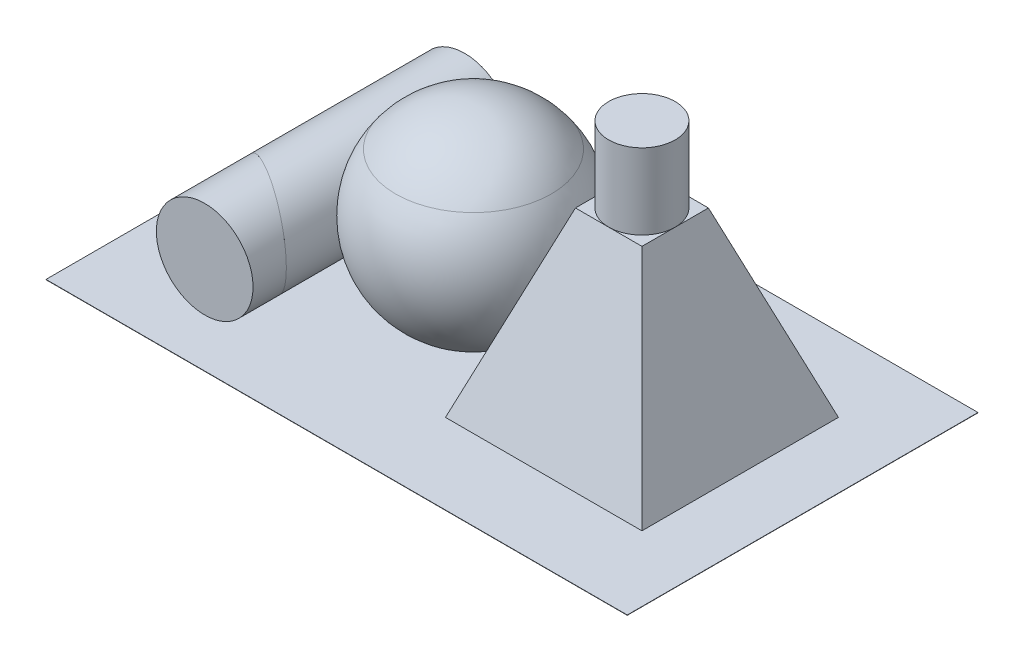
from build123d import *

# Parameters (mm, degrees)
BOSS_EXTRUDE1_DEPTH = 32.5
CUT_EXTRUDE1_DEPTH  = 95.240384125
SKETCH5_R           = 16
BOSS_EXTRUDE2_DEPTH = 43
CUT_EXTRUDE2_DEPTH  = 114.773628326
BOSS_EXTRUDE3_REACH = 137.983
SKETCH7_R           = 16
SKETCH8_R           = 11
BOSS_EXTRUDE4_DEPTH = 25
SKETCH9_W           = 192.296560702
SKETCH9_H           = 116.033958803
BOSS_EXTRUDE5_DEPTH = 0.1


with BuildPart() as part:
    # Sketch1 → Boss-Extrude1 (new, symmetric)
    with BuildSketch(Plane.XY):
        Polygon((0, 0), (65, 0), (43.5, 60), (21.5, 60), align=None)
    extrude(amount=BOSS_EXTRUDE1_DEPTH, both=True)

    # Sketch2 → Cut-Extrude1 (cut, through all)
    with BuildSketch(Plane(origin=(0, 0, 0), x_dir=(0, 0, -1), z_dir=(1, 0, 0))):
        Polygon((11, 60), (32.5, 60), (32.5, 0), align=None)
        Polygon((-32.5, 0), (-11, 60), (-32.5, 60), align=None)
    extrude(amount=CUT_EXTRUDE1_DEPTH, mode=Mode.SUBTRACT)

    # Sketch8 → Boss-Extrude4 (add)
    with BuildSketch(Plane(origin=(0, 60, 0), x_dir=(1, 0, 0), z_dir=(0, 1, 0))):
        with Locations(Location((32.5, 0, 0), (0, 0, 270))):
            Circle(SKETCH8_R)
    extrude(amount=BOSS_EXTRUDE4_DEPTH)


with BuildPart() as body_2:
    # Sketch3 → Revolve1 (revolve)
    with BuildSketch(Plane.XY):
        with BuildLine():
            Line((-12.106888729, 0), (-23.242417455, 0))
            Line((-23.242417455, 0), (-23.242417455, 49))
            Line((-23.242417455, 49), (2.506368924, 49))
            ThreePointArc((2.506368924, 49), (7.422924141, 20.854682903), (-12.106888729, 0))
        make_face()
    revolve(axis=Axis((-23.242417455, 0, 0), (0, 1, 0)))


with BuildPart() as body_3:
    # Sketch4 → Revolve2 (revolve)
    with BuildSketch(Plane.XY):
        with BuildLine():
            Line((-23.242417455, 49), (2.506368924, 49))
            ThreePointArc((2.506368924, 49), (-8.820212353, 58.565713714), (-23.242417455, 62))
            Line((-23.242417455, 62), (-23.242417455, 49))
        make_face()
    revolve(axis=Axis((-23.242417455, 49, 0), (0, 1, 0)))


with BuildPart() as body_4:
    # Sketch5 → Boss-Extrude2 (new, symmetric)
    with BuildSketch(Plane.XY):
        with Locations((-69.155378588, 16)):
            Circle(SKETCH5_R)
    extrude(amount=BOSS_EXTRUDE2_DEPTH, both=True)

    # Sketch6 → Cut-Extrude2 (cut, through all)
    with BuildSketch(Plane(origin=(0, 0, 0), x_dir=(1, 0, 0), z_dir=(0, 1, 0))):
        Polygon((-53.155378588, -32), (-93.662728042, -8.613070889), (-93.662728042, -63.183775795), (-40.15438586, -61.061315458), align=None)
    extrude(amount=CUT_EXTRUDE2_DEPTH, mode=Mode.SUBTRACT)


with BuildPart() as body_5:
    # Boss-Extrude3: up to this plane
    boss_extrude3_end = Plane(origin=(-53.155378588, 62, 32), z_dir=(-0.4999999999999979, 0, 0.8660254037844399))
    # Sketch7 → Boss-Extrude3 (new, up to the surface)
    with BuildSketch(Plane.XY.offset(43), mode=Mode.PRIVATE) as boss_extrude3_sk1:
        with Locations((-69.155378588, 16)):
            Circle(SKETCH7_R)
    boss_extrude3_tool1 = split(extrude(boss_extrude3_sk1.sketch, amount=-BOSS_EXTRUDE3_REACH, mode=Mode.PRIVATE), bisect_by=boss_extrude3_end, keep=Keep.BOTH, mode=Mode.PRIVATE)
    add(boss_extrude3_tool1.solids().sort_by_distance((-69.155379, 16, 43))[0])


with BuildPart() as body_6:
    # Sketch9 → Boss-Extrude5 (new body)
    with BuildSketch(Plane(origin=(0, 0, 0), x_dir=(1, 0, 0), z_dir=(0, 1, 0))):
        with Locations((-9.462668311, -1.025034971)):
            Rectangle(SKETCH9_W, SKETCH9_H)
    extrude(amount=-BOSS_EXTRUDE5_DEPTH)


solid = Compound([part.part, body_2.part, body_3.part, body_4.part, body_5.part, body_6.part])
